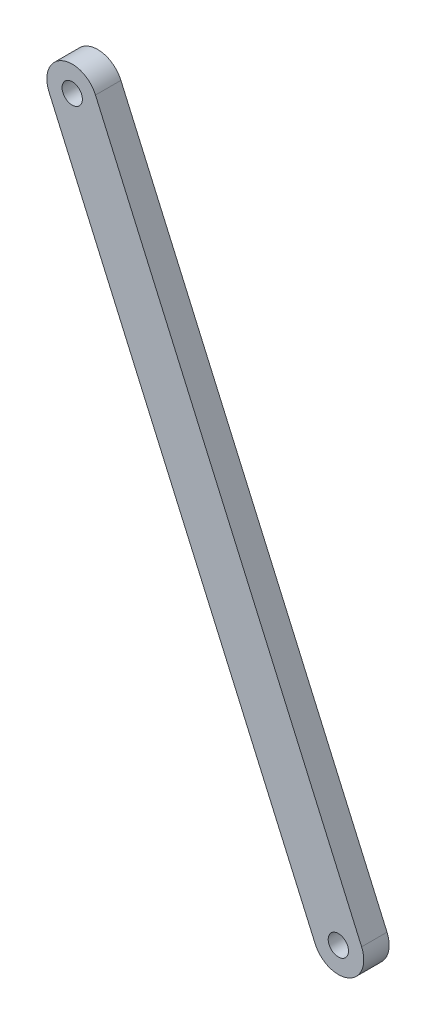
from build123d import *

# Parameters (mm, degrees)
BOSS_EXTRUDE1_START = 5
SKETCH1_R           = 2
BOSS_EXTRUDE1_DEPTH = 5


with BuildPart() as part:
    # Sketch1 → Boss-Extrude1 (new body)
    with BuildSketch(Plane.XY.offset(BOSS_EXTRUDE1_START)):
        with BuildLine():
            Line((-65.644060537, 162.800249417), (-13.275181806, 43.814953937))
            ThreePointArc((-13.275181806, 43.814953937), (-15.837351681, 37.224408775), (-22.427896843, 39.78657865))
            Line((-22.427896843, 39.78657865), (-74.796775574, 158.77187413))
            ThreePointArc((-74.796775574, 158.77187413), (-72.234605699, 165.362419292), (-65.644060537, 162.800249417))
        make_face()
        with Locations((-70.220418055, 160.786061774)):
            Circle(SKETCH1_R, mode=Mode.SUBTRACT)
        with Locations((-17.851539324, 41.800766294)):
            Circle(SKETCH1_R, mode=Mode.SUBTRACT)
    extrude(amount=BOSS_EXTRUDE1_DEPTH)


solid = part.part
